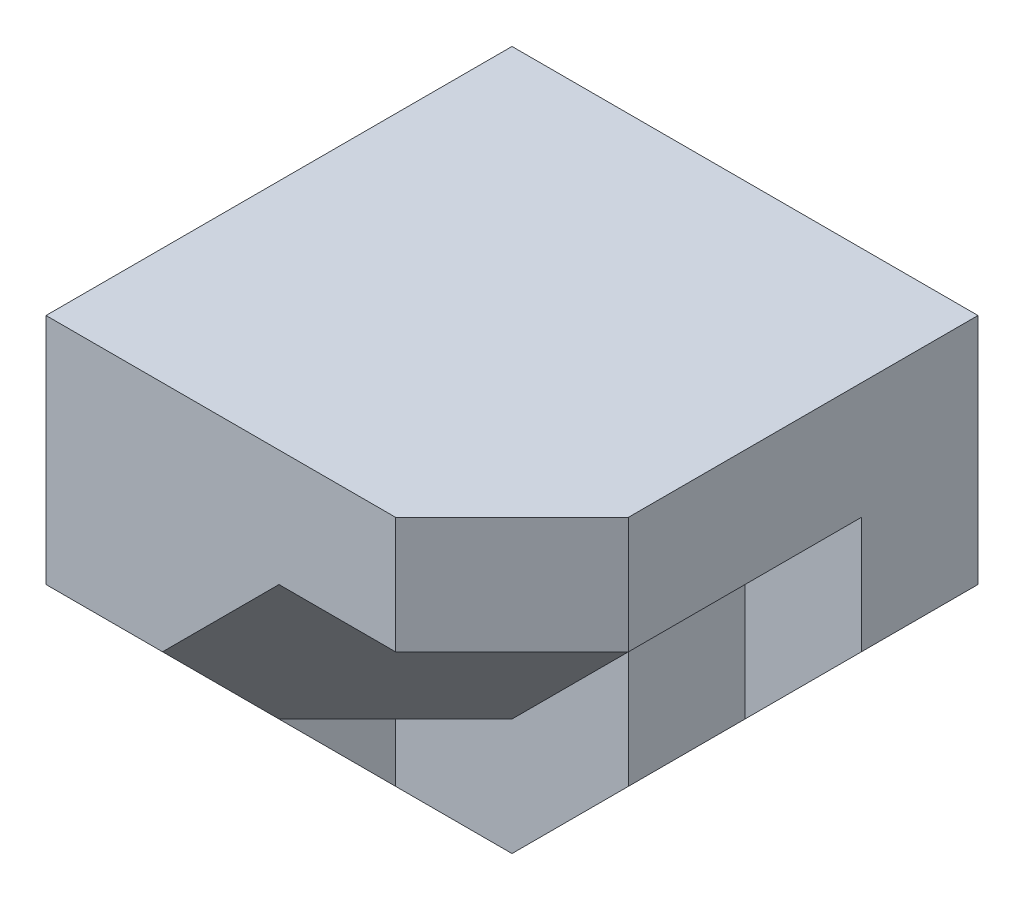
from build123d import *

# Parameters (mm, degrees)
SKETCH1_W           = 40
SKETCH1_H           = 40
BOSS_EXTRUDE1_DEPTH = 20
CUT_EXTRUDE1_DEPTH  = 20
CUT_EXTRUDE2_DEPTH  = 10
SKETCH4_W           = 20
SKETCH4_H           = 10
BOSS_EXTRUDE2_DEPTH = 40
CUT_EXTRUDE3_DEPTH  = 40
SKETCH6_W           = 20
SKETCH6_H           = 10
BOSS_EXTRUDE3_DEPTH = 10
BOSS_EXTRUDE4_DEPTH = 10
BOSS_EXTRUDE5_DEPTH = 27
BOSS_EXTRUDE6_DEPTH = 20
CUT_EXTRUDE4_DEPTH  = 20


with BuildPart() as part:
    # Sketch1 → Boss-Extrude1 (new body)
    with BuildSketch(Plane.XY):
        with Locations((20, 20)):
            Rectangle(SKETCH1_W, SKETCH1_H)
    extrude(amount=BOSS_EXTRUDE1_DEPTH)

    # Sketch2 → Cut-Extrude1 (cut)
    with BuildSketch(Plane.XY.offset(20)):
        Polygon((20, 0), (40, 20), (40, 0), align=None)
    extrude(amount=-CUT_EXTRUDE1_DEPTH, mode=Mode.SUBTRACT)

    # Sketch3 → Cut-Extrude2 (cut)
    with BuildSketch(Plane.XY.offset(20)):
        Polygon((30, 20), (30, 10), (40, 20), (40, 30), align=None)
    extrude(amount=-CUT_EXTRUDE2_DEPTH, mode=Mode.SUBTRACT)

    # Sketch4 → Boss-Extrude2 (add)
    with BuildSketch(Plane(origin=(40, 0, 0), x_dir=(0, 0, -1), z_dir=(1, 0, 0))):
        with Locations((-30, 35)):
            Rectangle(SKETCH4_W, SKETCH4_H)
    extrude(amount=-BOSS_EXTRUDE2_DEPTH)

    # Sketch5 → Cut-Extrude3 (cut)
    with BuildSketch(Plane(origin=(0, 30, 0), x_dir=(-1, 0, 0), z_dir=(0, -1, 0))):
        Polygon((-30, -40), (-40, -40), (-40, -30), align=None)
    extrude(amount=-CUT_EXTRUDE3_DEPTH, mode=Mode.SUBTRACT)

    # Sketch6 → Boss-Extrude3 (add)
    with BuildSketch(Plane.ZY):
        with Locations((30, 25)):
            Rectangle(SKETCH6_W, SKETCH6_H)
    extrude(amount=-BOSS_EXTRUDE3_DEPTH)

    # Sketch7 → Boss-Extrude4 (add)
    with BuildSketch(Plane.ZY):
        Polygon((30, 20), (30, 10), (20, 0), (20, 20), align=None)
    extrude(amount=-BOSS_EXTRUDE4_DEPTH)

    # Sketch8 → Boss-Extrude5 (add)
    with BuildSketch(Plane.XY.offset(40)):
        Polygon((10, 20), (20, 30), (10, 30), align=None)
    extrude(amount=-BOSS_EXTRUDE5_DEPTH)

    # Sketch9 → Boss-Extrude6 (add)
    with BuildSketch(Plane.XY.offset(20)):
        Polygon((10, 20), (20, 30), (40, 30), (30, 20), (20, 10), (10, 10), align=None)
    extrude(amount=BOSS_EXTRUDE6_DEPTH)

    # 3DSketch1 → Cut-Extrude4 (cut, along a direction that is not the sketch's normal)
    with BuildSketch(Plane(origin=(20, 30, 40), x_dir=(0.7071067811865471, 0, -0.7071067811865479), z_dir=(-0.5773502691896258, 0.5773502691896264, -0.5773502691896252))):
        Polygon((0, 0), (28.284271247, 0), (14.142135624, 24.494897428), (0, 24.494897428), (-7.071067812, 12.247448714), align=None)
    extrude(amount=-CUT_EXTRUDE4_DEPTH, dir=(-1, 0, 0), mode=Mode.SUBTRACT)


with BuildPart() as body_2:
    # of the pieces the cut leaves, the one that is kept (cut_extrude4_keep)
    add(part.part.solids().sort_by_distance((0, 0, 0))[0])


solid = body_2.part
